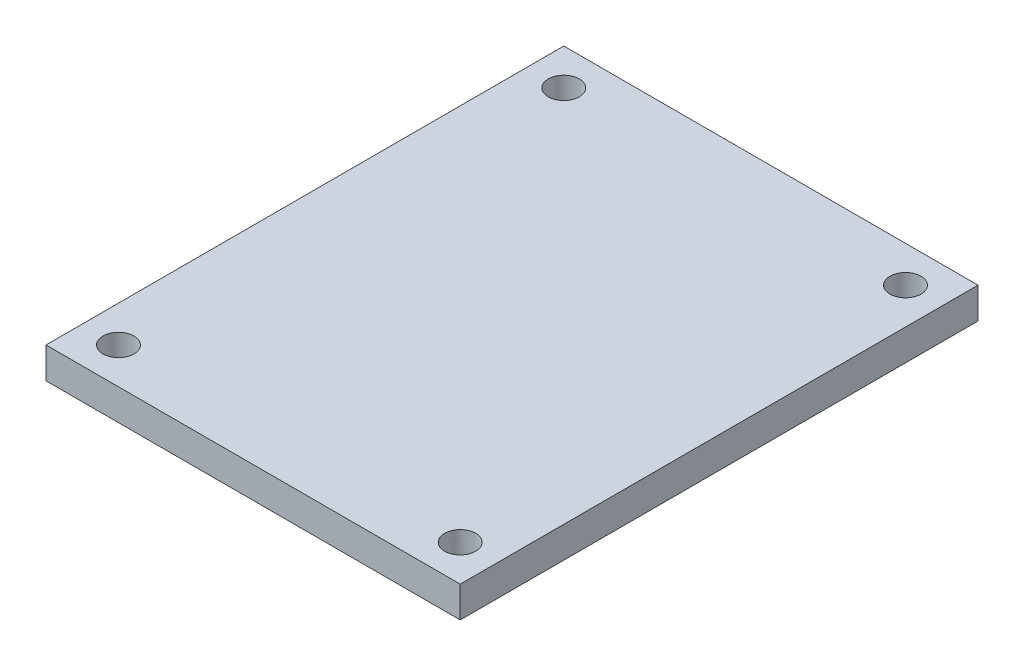
from build123d import *

# Parameters (mm, degrees)
CROQUIS2_W              = 508
CROQUIS2_H              = 635
SALIENTE_EXTRUIR2_DEPTH = 38.1
CROQUIS3_R              = 19.05
CORTAR_EXTRUIR1_DEPTH   = 38.1


with BuildPart() as part:
    # Croquis2 → Saliente-Extruir2 (new body)
    with BuildSketch(Plane(origin=(0, 0, 0), x_dir=(1, 0, 0), z_dir=(0, 1, 0))):
        Rectangle(CROQUIS2_W, CROQUIS2_H)
    extrude(amount=SALIENTE_EXTRUIR2_DEPTH)

    # Croquis3 → Cortar-Extruir1 (cut)
    with BuildSketch(Plane(origin=(0, 38.1, 0), x_dir=(1, 0, 0), z_dir=(0, 1, 0))):
        with Locations((-209.55, 273.05)):
            Circle(CROQUIS3_R)
        with Locations((209.55, 273.05)):
            Circle(CROQUIS3_R)
        with Locations((209.55, -273.05)):
            Circle(CROQUIS3_R)
        with Locations((-209.55, -273.05)):
            Circle(CROQUIS3_R)
    extrude(amount=-CORTAR_EXTRUIR1_DEPTH, mode=Mode.SUBTRACT)


solid = part.part
